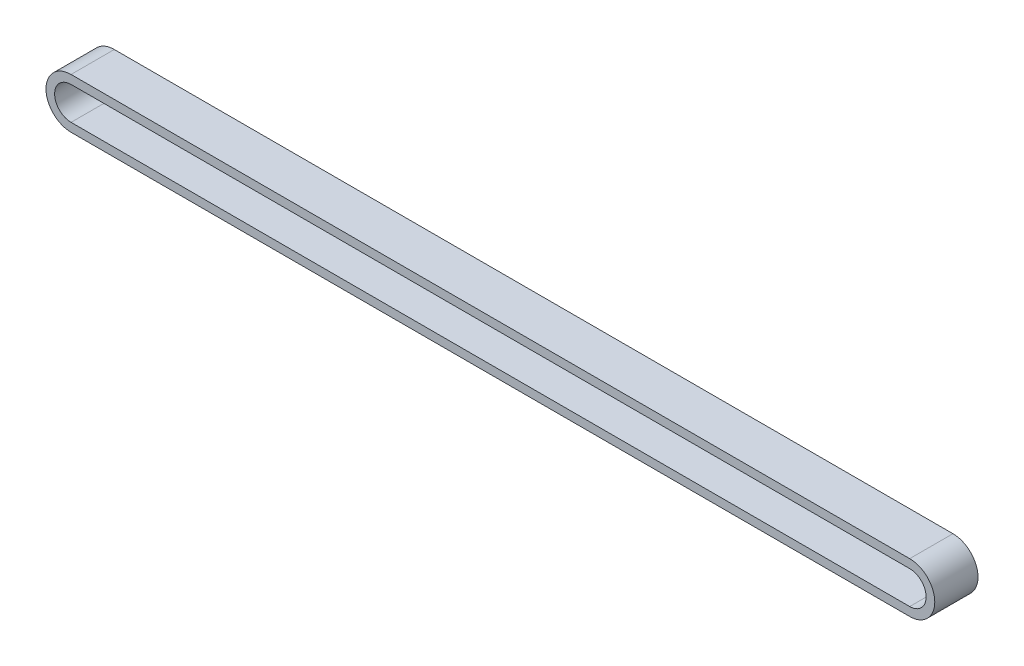
from build123d import *

# Parameters (mm, degrees)
BOSS_EXTRUDE1_DEPTH = 10


with BuildPart() as part:
    # Sketch1 → Boss-Extrude1 (new body)
    with BuildSketch(Plane.XY):
        with BuildLine():
            Line((-204.016557459, -4.219470759), (-10.016557459, -4.219470759))
            ThreePointArc((-10.016557459, -4.219470759), (-4.219470759, -10.016557459), (-10.016557459, -15.813644159))
            Line((-10.016557459, -15.813644159), (-204.016557459, -15.813644159))
            ThreePointArc((-204.016557459, -15.813644159), (-209.813644159, -10.016557459), (-204.016557459, -4.219470759))
        make_face()
        with BuildLine():
            Line((-204.016557459, -6.219470759), (-10.016557459, -6.219470759))
            ThreePointArc((-10.016557459, -6.219470759), (-6.219470759, -10.016557459), (-10.016557459, -13.813644159))
            Line((-10.016557459, -13.813644159), (-204.016557459, -13.813644159))
            ThreePointArc((-204.016557459, -13.813644159), (-207.813644159, -10.016557459), (-204.016557459, -6.219470759))
        make_face(mode=Mode.SUBTRACT)
    extrude(amount=BOSS_EXTRUDE1_DEPTH)


solid = part.part
